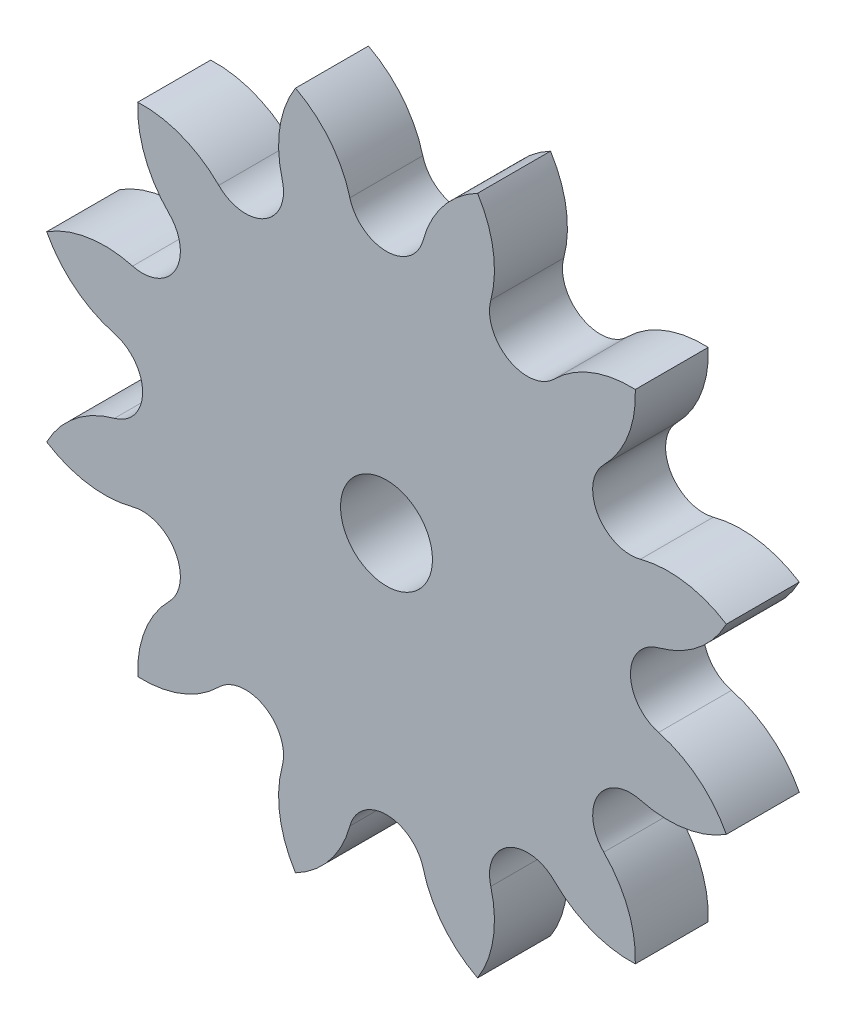
from build123d import *

# Parameters (mm, degrees)
SKETCH2_R           = 2
BOSS_EXTRUDE2_DEPTH = 3.175


with BuildPart() as part:
    # Sketch2 → Boss-Extrude2 (new body)
    with BuildSketch(Plane.XY):
        with BuildLine():
            ThreePointArc((9.456794765, 7.302125235), (10.51328966, 8.920913041), (10.82870315, 10.828049574))
            ThreePointArc((10.82870315, 10.828049574), (8.921045244, 10.513465667), (7.301533296, 9.457386704))
            ThreePointArc((7.301533296, 9.457386704), (5.308889045, 9.194845217), (4.539183834, 11.051485471))
            ThreePointArc((4.539183834, 11.051485471), (4.64471403, 12.981928422), (3.964051405, 14.791471183))
            ThreePointArc((3.964051405, 14.791471183), (2.469674584, 13.565372247), (1.59532555, 11.841424903))
            ThreePointArc((1.59532555, 11.841424903), (0.000409384, 10.617090374), (-1.594506782, 11.841424903))
            ThreePointArc((-1.594506782, 11.841424903), (-2.468043552, 13.565085875), (-3.961395494, 14.791451895))
            ThreePointArc((-3.961395494, 14.791451895), (-4.64300424, 12.982116437), (-4.538365066, 11.051485471))
            ThreePointArc((-4.538365066, 11.051485471), (-5.308070277, 9.194845217), (-7.300714528, 9.457386704))
            ThreePointArc((-7.300714528, 9.457386704), (-8.919846484, 10.513683908), (-10.827230806, 10.82870315))
            ThreePointArc((-10.827230806, 10.82870315), (-10.512252617, 8.921293027), (-9.455975997, 7.302125235))
            ThreePointArc((-9.455975997, 7.302125235), (-9.19343451, 5.309480984), (-11.050074764, 4.539775774))
            ThreePointArc((-11.050074764, 4.539775774), (-12.980517715, 4.64530597), (-14.790060475, 3.964643344))
            ThreePointArc((-14.790060475, 3.964643344), (-13.56396154, 2.470266524), (-11.840014195, 1.595917489))
            ThreePointArc((-11.840014195, 1.595917489), (-10.615679667, 0.001001323), (-11.840014195, -1.593914842))
            ThreePointArc((-11.840014195, -1.593914842), (-13.563675168, -2.467451613), (-14.790041187, -3.960803554))
            ThreePointArc((-14.790041187, -3.960803554), (-12.980705729, -4.6424123), (-11.050074764, -4.537773127))
            ThreePointArc((-11.050074764, -4.537773127), (-9.19343451, -5.307478337), (-9.455975997, -7.300122588))
            ThreePointArc((-9.455975997, -7.300122588), (-10.512273201, -8.919254544), (-10.827292443, -10.826638866))
            ThreePointArc((-10.827292443, -10.826638866), (-8.91988232, -10.511660678), (-7.300714528, -9.455384057))
            ThreePointArc((-7.300714528, -9.455384057), (-5.308070277, -9.19284257), (-4.538365066, -11.049482824))
            ThreePointArc((-4.538365066, -11.049482824), (-4.643895262, -12.979925775), (-3.963232637, -14.789468536))
            ThreePointArc((-3.963232637, -14.789468536), (-2.468855816, -13.5633696), (-1.594506782, -11.839422256))
            ThreePointArc((-1.594506782, -11.839422256), (0.000409384, -10.615087727), (1.59532555, -11.839422256))
            ThreePointArc((1.59532555, -11.839422256), (2.46886232, -13.563083228), (3.962214262, -14.789449248))
            ThreePointArc((3.962214262, -14.789449248), (4.643823008, -12.98011379), (4.539183834, -11.049482824))
            ThreePointArc((4.539183834, -11.049482824), (5.308889045, -9.19284257), (7.301533296, -9.455384057))
            ThreePointArc((7.301533296, -9.455384057), (8.920665252, -10.511681261), (10.828049574, -10.826700503))
            ThreePointArc((10.828049574, -10.826700503), (10.513071385, -8.91929038), (9.456794765, -7.300122588))
            ThreePointArc((9.456794765, -7.300122588), (9.194253278, -5.307478337), (11.050893532, -4.537773127))
            ThreePointArc((11.050893532, -4.537773127), (12.981336483, -4.643303323), (14.790879243, -3.962640697))
            ThreePointArc((14.790879243, -3.962640697), (13.564780308, -2.468263877), (11.840832964, -1.593914842))
            ThreePointArc((11.840832964, -1.593914842), (10.617899153, 0.000932392), (11.841424903, 1.59532555))
            ThreePointArc((11.841424903, 1.59532555), (13.565085875, 2.46886232), (14.791451895, 3.962214262))
            ThreePointArc((14.791451895, 3.962214262), (12.982116437, 4.643823008), (11.051485471, 4.539183834))
            ThreePointArc((11.051485471, 4.539183834), (9.193282623, 5.308357949), (9.456794765, 7.302125235))
        make_face()
        Circle(SKETCH2_R, mode=Mode.SUBTRACT)
    extrude(amount=BOSS_EXTRUDE2_DEPTH)


solid = part.part
